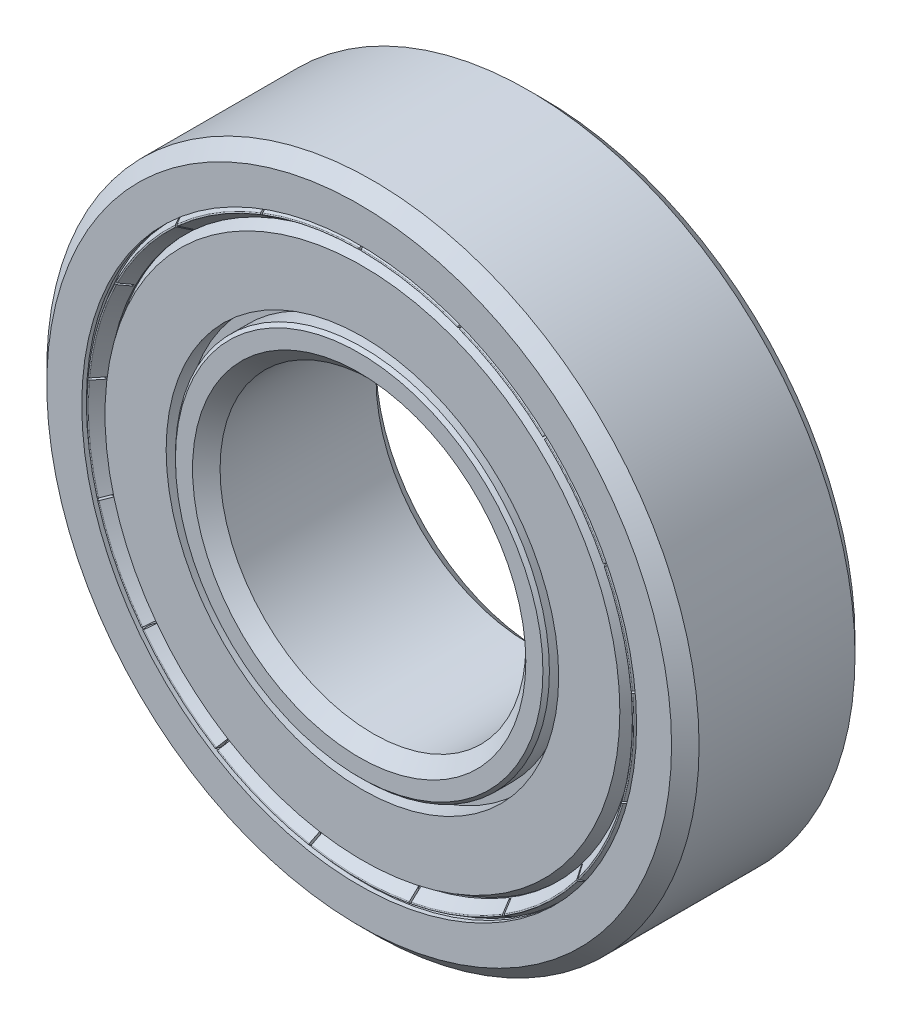
from build123d import *

# Parameters (mm, degrees)
CIRPATTERN1_COUNT  = 8
FILLET1_R          = 0.045
CUT_EXTRUDE1_START = 3.92899
CUT_EXTRUDE1_DEPTH = 1.57101
CIRPATTERN2_COUNT  = 17


with BuildPart() as part:
    # Sketch3 → Revolve1 (revolve)
    with BuildSketch(Plane(origin=(0, 0, 0), x_dir=(0, 0, -1), z_dir=(1, 0, 0))):
        with BuildLine():
            Line((3.825, 16), (-3.825, 16))
            Line((-3.825, 16), (-4.5, 15.325))
            Line((-4.5, 15.325), (-4.5, 13.609653101))
            Line((-4.5, 13.609653101), (-4.275, 13.609653101))
            Line((-4.275, 13.609653101), (-4.275, 14.16732655))
            Line((-4.275, 14.16732655), (-4.115900974, 14.326425576))
            Line((-4.115900974, 14.326425576), (-1.4875, 14.326425576))
            ThreePointArc((-1.4875, 14.326425576), (0, 14.725), (1.4875, 14.326425576))
            Line((1.4875, 14.326425576), (4.115900974, 14.326425576))
            Line((4.115900974, 14.326425576), (4.275, 14.16732655))
            Line((4.275, 14.16732655), (4.275, 13.609653101))
            Line((4.275, 13.609653101), (4.5, 13.609653101))
            Line((4.5, 13.609653101), (4.5, 15.325))
            Line((4.5, 15.325), (3.825, 16))
        make_face()
        with BuildLine():
            Line((3.825, 7.5), (-3.825, 7.5))
            Line((-3.825, 7.5), (-4.5, 8.175))
            Line((-4.5, 8.175), (-4.5, 9.014475398))
            Line((-4.5, 9.014475398), (-4.340900974, 9.173574424))
            Line((-4.340900974, 9.173574424), (-1.4875, 9.173574424))
            ThreePointArc((-1.4875, 9.173574424), (0, 8.775), (1.4875, 9.173574424))
            Line((1.4875, 9.173574424), (4.340900974, 9.173574424))
            Line((4.340900974, 9.173574424), (4.5, 9.014475398))
            Line((4.5, 9.014475398), (4.5, 8.175))
            Line((4.5, 8.175), (3.825, 7.5))
        make_face()
    revolve(axis=Axis((0, 0, 4.5), (0, 0, -1)))


with BuildPart() as body_2:
    # Sketch4 → Revolve2 (revolve)
    with BuildSketch(Plane(origin=(0, 0, 0), x_dir=(0, 0, -1), z_dir=(1, 0, 0))):
        with BuildLine():
            Line((0, 14.725), (0, 8.775))
            ThreePointArc((0, 8.775), (-2.975, 11.75), (0, 14.725))
        make_face()
    revolve(axis=Axis((0, 16, 0), (0, -1, 0)))


with BuildPart() as cirpattern1_1:
    # CirPattern1: pattern copy
    add(body_2.part.rotate(Axis((0, 0, 0), (0, 0, 1)), 1 * 360 / CIRPATTERN1_COUNT))


with BuildPart() as cirpattern1_2:
    # CirPattern1: pattern copy
    add(body_2.part.rotate(Axis((0, 0, 0), (0, 0, 1)), 2 * 360 / CIRPATTERN1_COUNT))


with BuildPart() as cirpattern1_3:
    # CirPattern1: pattern copy
    add(body_2.part.rotate(Axis((0, 0, 0), (0, 0, 1)), 3 * 360 / CIRPATTERN1_COUNT))


with BuildPart() as cirpattern1_4:
    # CirPattern1: pattern copy
    add(body_2.part.rotate(Axis((0, 0, 0), (0, 0, 1)), 4 * 360 / CIRPATTERN1_COUNT))


with BuildPart() as cirpattern1_5:
    # CirPattern1: pattern copy
    add(body_2.part.rotate(Axis((0, 0, 0), (0, 0, 1)), 5 * 360 / CIRPATTERN1_COUNT))


with BuildPart() as cirpattern1_6:
    # CirPattern1: pattern copy
    add(body_2.part.rotate(Axis((0, 0, 0), (0, 0, 1)), 6 * 360 / CIRPATTERN1_COUNT))


with BuildPart() as cirpattern1_7:
    # CirPattern1: pattern copy
    add(body_2.part.rotate(Axis((0, 0, 0), (0, 0, 1)), 7 * 360 / CIRPATTERN1_COUNT))


with BuildPart() as body_10:
    # Sketch5 → Revolve3 (revolve)
    with BuildSketch(Plane(origin=(0, 0, 0), x_dir=(0, 0, -1), z_dir=(1, 0, 0))):
        Polygon((-2.975, 9.173574424), (-3.430300325, 9.173574424), (-3.430300325, 9.628874748), (-4.340900974, 9.628874748), (-4.340900974, 12.628617246), (-3.430300325, 13.154352776), (-2.975, 13.154352776), align=None)
        Polygon((3.430300325, 13.154352776), (2.975, 13.154352776), (2.975, 9.173574424), (3.430300325, 9.173574424), (3.430300325, 9.628874748), (4.340900974, 9.628874748), (4.340900974, 12.628617246), align=None)
    revolve(axis=Axis((0, 0, 4.5), (0, 0, -1)))


with BuildPart() as body_11:
    # Sketch6 → Revolve4 (revolve)
    with BuildSketch(Plane(origin=(0, 0, 0), x_dir=(0, 0, -1), z_dir=(1, 0, 0))):
        Polygon((-3.751730535, 13.609653101), (-4.10625, 13.609653101), (-4.5, 13.382321432), (-3.886730535, 12.95290553), (-3.841730535, 12.95290553), (-3.751730535, 12.968774958), align=None)
    revolve(axis=Axis((0, 0, 4.5), (0, 0, -1)))

    # Fillet1
    fillet1_edges = [body_11.edges().sort_by_distance(p)[0] for p in [
        (0, -13.382321432, 4.5),
    ]]
    fillet(fillet1_edges, radius=FILLET1_R)

    # Sketch7 → Cut-Extrude1 (cut, through all)
    with BuildSketch(Plane.XY.offset(CUT_EXTRUDE1_START)):
        Polygon((-0.05, 13.609653101), (-0.05, 13.709653101), (0.05, 13.709653101), (0.05, 13.609653101), (0.05, 12.95290553), (0.05, 12.85290553), (-0.05, 12.85290553), (-0.05, 12.95290553), align=None)
    cut_extrude1 = extrude(amount=CUT_EXTRUDE1_DEPTH, mode=Mode.SUBTRACT)

    # CirPattern2: Cut-Extrude1 ×17 about axis
    cirpattern2_axis = Axis((0, 0, 0), (0, 0, 1))
    for i in range(1, CIRPATTERN2_COUNT):
        add(cut_extrude1.rotate(cirpattern2_axis, i * 360 / CIRPATTERN2_COUNT), mode=Mode.SUBTRACT)


with BuildPart() as body_12:
    # Mirror1: mirrored copy
    add(body_11.part.mirror(Plane.XY))


solid = Compound([part.part, body_2.part, cirpattern1_1.part, cirpattern1_2.part, cirpattern1_3.part, cirpattern1_4.part, cirpattern1_5.part, cirpattern1_6.part, cirpattern1_7.part, body_10.part, body_11.part, body_12.part])
